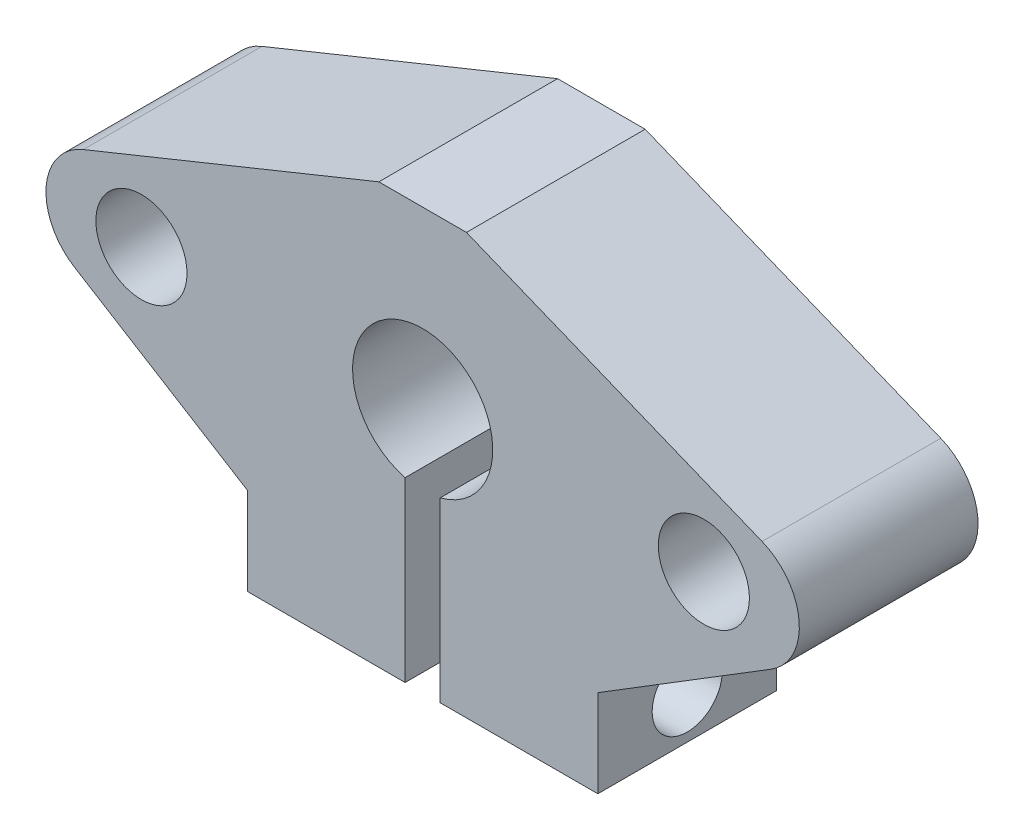
from build123d import *

# Parameters (mm, degrees)
CROQUIS1_R                 = 4
CROQUIS1_R_2               = 2.6
SALIENTE_EXTRUIR2_DEPTH    = 10.2
CORTAR_EXTRUIR3_DEPTH      = 11.2
CROQUIS4_R                 = 2
CORTAR_EXTRUIR4_DEPTH      = 12.5
CORTAR_EXTRUIR4_DEPTH_BACK = 32.5


with BuildPart() as part:
    # Croquis1 → Saliente-Extruir2 (new body)
    with BuildSketch(Plane.XY):
        with BuildLine():
            Line((-10, 0), (10, 0))
            Line((10, 0), (10, 5))
            Line((10, 5), (19.881270341, 11.098702893))
            ThreePointArc((19.881270341, 11.098702893), (21.48800967, 14.28568517), (19.37161624, 17.15959299))
            Line((19.37161624, 17.15959299), (2.5, 24))
            Line((2.5, 24), (-2.5, 24))
            Line((-2.5, 24), (-19.37161624, 17.15959299))
            ThreePointArc((-19.37161624, 17.15959299), (-21.48800967, 14.28568517), (-19.881270341, 11.098702893))
            Line((-19.881270341, 11.098702893), (-10, 5))
            Line((-10, 5), (-10, 0))
        make_face()
        with Locations((0, 14)):
            Circle(CROQUIS1_R, mode=Mode.SUBTRACT)
        with Locations((16.05, 14)):
            Circle(CROQUIS1_R_2, mode=Mode.SUBTRACT)
        with Locations((-16.05, 14)):
            Circle(CROQUIS1_R_2, mode=Mode.SUBTRACT)
    extrude(amount=SALIENTE_EXTRUIR2_DEPTH)

    # Croquis3 → Cortar-Extruir3 (cut, through all)
    with BuildSketch(Plane.XY.offset(10.2)):
        with BuildLine():
            Line((-1, 0), (-1, 10.127016654))
            ThreePointArc((-1, 10.127016654), (0, 10), (1, 10.127016654))
            Line((1, 10.127016654), (1, 0))
            Line((1, 0), (-1, 0))
        make_face()
    extrude(amount=-CORTAR_EXTRUIR3_DEPTH, mode=Mode.SUBTRACT)

    # Croquis4 → Cortar-Extruir4 (cut, two sides)
    with BuildSketch(Plane(origin=(10, 0, 0), x_dir=(0, 0, -1), z_dir=(1, 0, 0))) as cortar_extruir4_sk:
        with Locations((-5.1, 2.5)):
            Circle(CROQUIS4_R)
    extrude(amount=CORTAR_EXTRUIR4_DEPTH, mode=Mode.SUBTRACT)
    extrude(cortar_extruir4_sk.sketch, amount=-CORTAR_EXTRUIR4_DEPTH_BACK, mode=Mode.SUBTRACT)


solid = part.part
